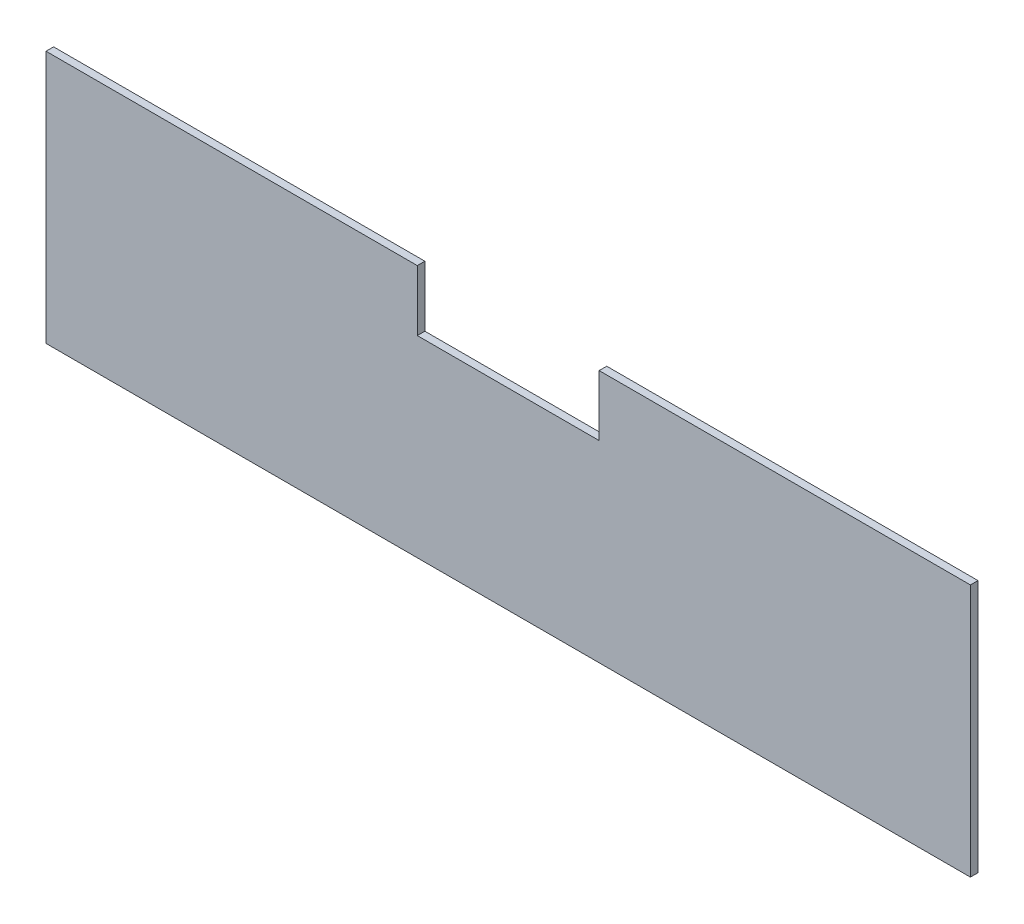
from build123d import *

# Parameters (mm, degrees)
BOSS_EXTRUDE1_DEPTH = 3.175


with BuildPart() as part:
    # Sketch1 → Boss-Extrude1 (new body)
    with BuildSketch(Plane.XY):
        Polygon((38.1, 53.0225), (193.675, 53.0225), (193.675, -53.0225), (-193.675, -53.0225), (-193.675, 53.0225), (-38.1, 53.0225), (-38.1, 27.6225), (38.1, 27.6225), align=None)
    extrude(amount=BOSS_EXTRUDE1_DEPTH)


solid = part.part
